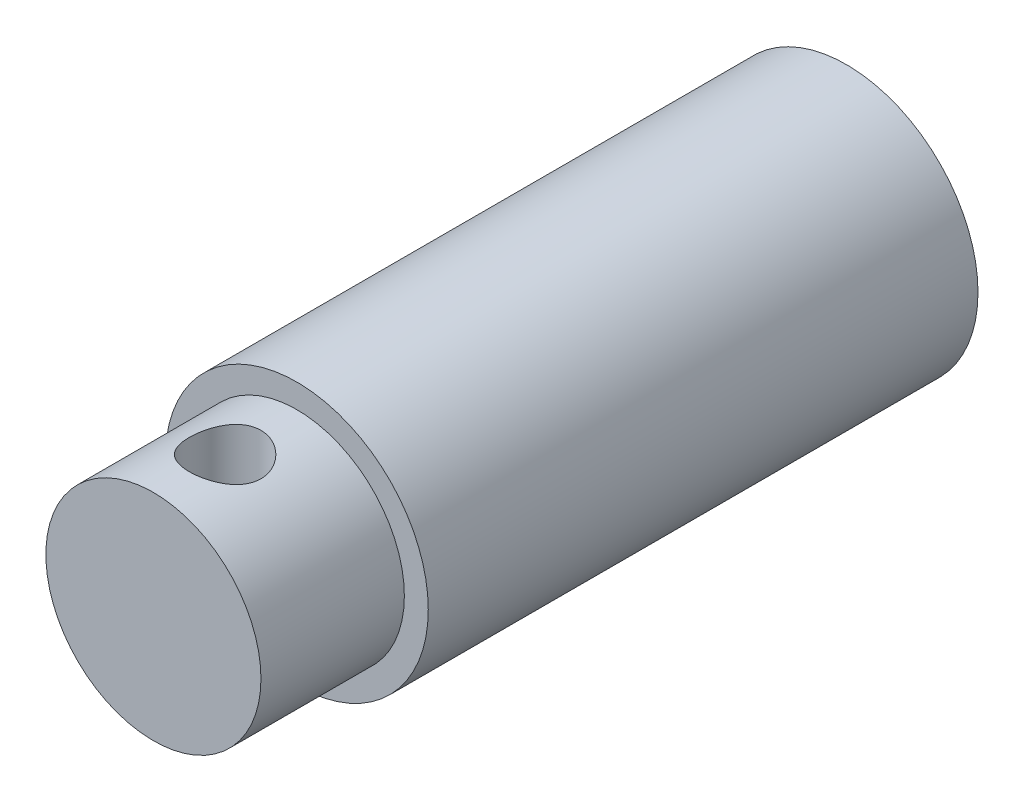
from build123d import *

# Parameters (mm, degrees)
SKETCH1_R               = 5.5
BOSS_EXTRUDE1_DEPTH     = 23
SKETCH2_R               = 4.5
BOSS_EXTRUDE2_DEPTH     = 6
SKETCH3_R               = 1.5
CUT_EXTRUDE1_DEPTH      = 6.5
CUT_EXTRUDE1_DEPTH_BACK = 6.5


with BuildPart() as part:
    # Sketch1 → Boss-Extrude1 (new body)
    with BuildSketch(Plane.XY):
        Circle(SKETCH1_R)
    extrude(amount=BOSS_EXTRUDE1_DEPTH)

    # Sketch2 → Boss-Extrude2 (add)
    with BuildSketch(Plane.XY.offset(23)):
        Circle(SKETCH2_R)
    extrude(amount=BOSS_EXTRUDE2_DEPTH)

    # Sketch3 → Cut-Extrude1 (cut, two sides)
    with BuildSketch(Plane(origin=(0, 0, 0), x_dir=(1, 0, 0), z_dir=(0, 1, 0))) as cut_extrude1_sk:
        with Locations((0, -26)):
            Circle(SKETCH3_R)
    extrude(amount=CUT_EXTRUDE1_DEPTH, mode=Mode.SUBTRACT)
    extrude(cut_extrude1_sk.sketch, amount=-CUT_EXTRUDE1_DEPTH_BACK, mode=Mode.SUBTRACT)


solid = part.part
